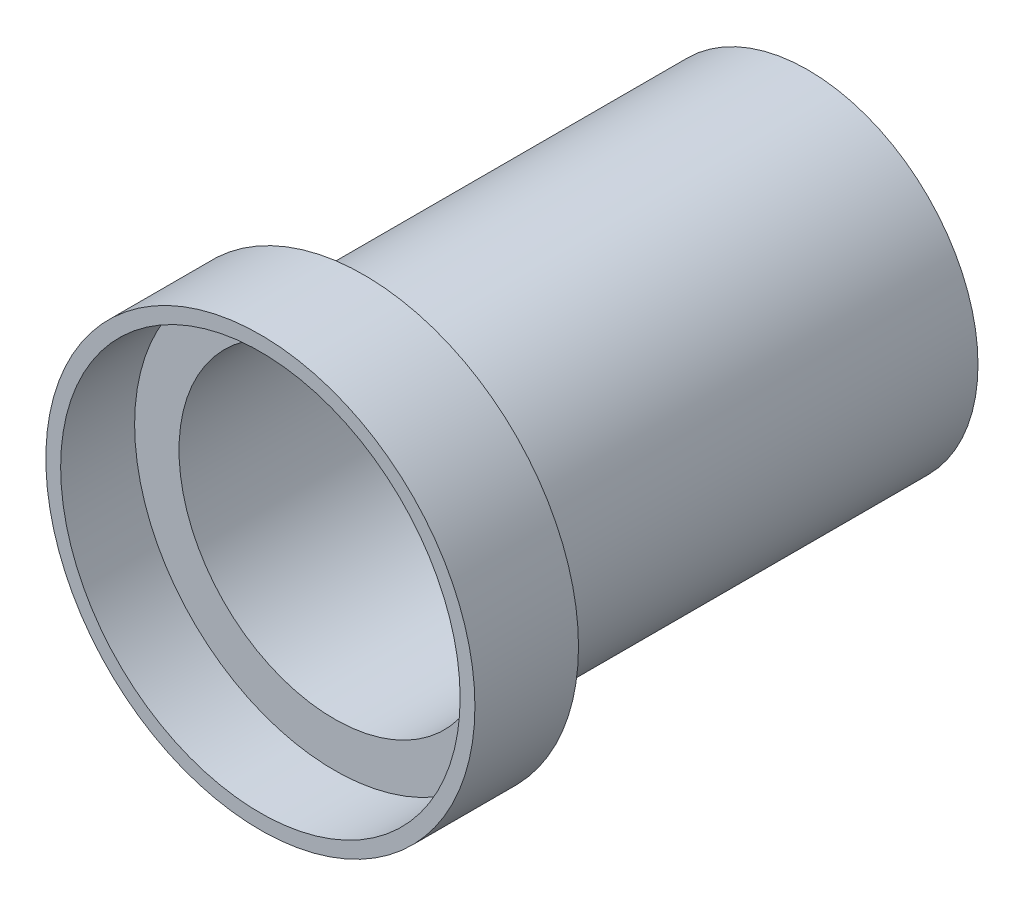
from build123d import *

# Parameters (mm, degrees)
SKETCH_1_R          = 11.5
EXTRUDE_1_DEPTH     = 30
SKETCH_3_R          = 14.5
EXTRUDE_2_DEPTH     = 7
SKETCH_4_R          = 13.5
CUT_EXTRUDE_3_DEPTH = 5
CUT_EXTRUDE_START   = 1
SKETCH_2_R          = 10.5
CUT_EXTRUDE_2_DEPTH = 37


with BuildPart() as part:
    # ｽｹｯﾁ1 → ﾎﾞｽ - 押し出し1 (new body)
    with BuildSketch(Plane.XY):
        Circle(SKETCH_1_R)
    extrude(amount=EXTRUDE_1_DEPTH)

    # ｽｹｯﾁ3 → ﾎﾞｽ - 押し出し2 (add)
    with BuildSketch(Plane.XY.offset(30)):
        Circle(SKETCH_3_R)
    extrude(amount=EXTRUDE_2_DEPTH)

    # ｽｹｯﾁ4 → ｶｯﾄ - 押し出し3 (cut)
    with BuildSketch(Plane.XY.offset(37)):
        Circle(SKETCH_4_R)
    extrude(amount=-CUT_EXTRUDE_3_DEPTH, mode=Mode.SUBTRACT)

    # ｽｹｯﾁ2 → ｶｯﾄ - 押し出し2 (cut, through all)
    with BuildSketch(Plane.XY.offset(CUT_EXTRUDE_START)):
        Circle(SKETCH_2_R)
    extrude(amount=CUT_EXTRUDE_2_DEPTH, mode=Mode.SUBTRACT)


solid = part.part
